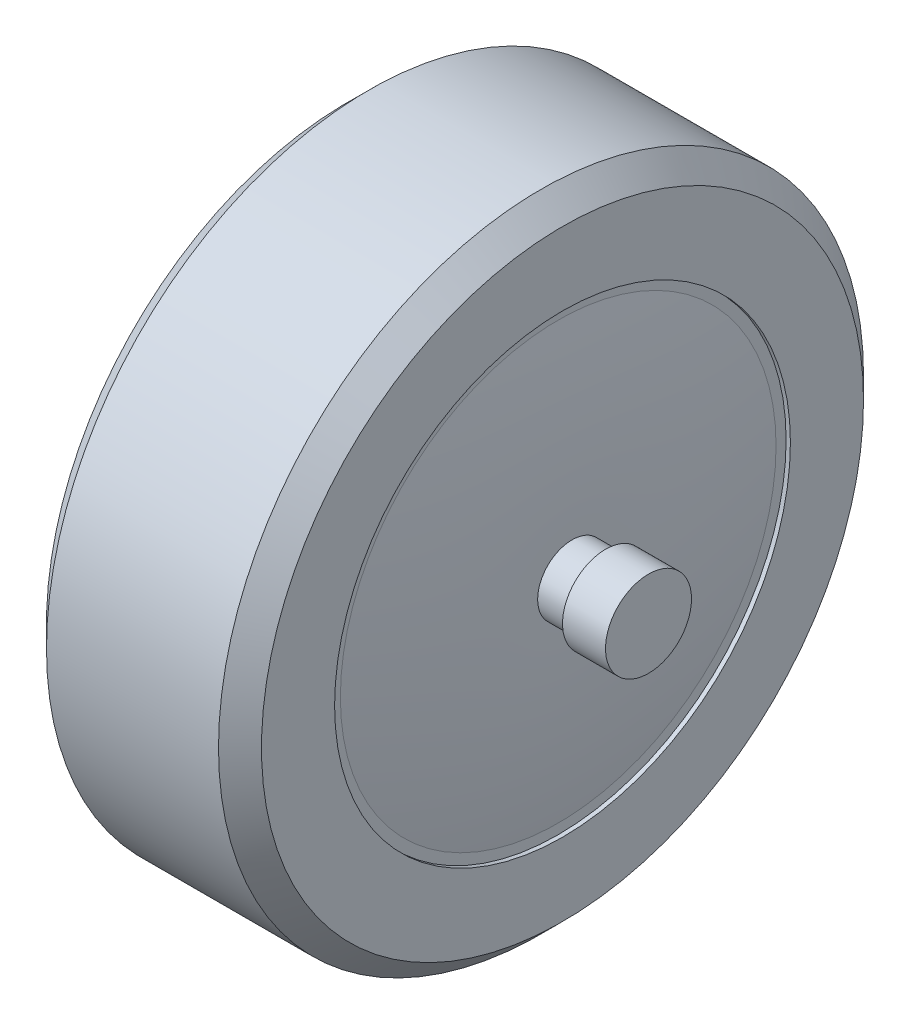
from build123d import *

# Parameters (mm, degrees)
SKETCH1_R           = 75
BOSS_EXTRUDE1_DEPTH = 25
SKETCH2_R           = 8
BOSS_EXTRUDE2_DEPTH = 35
SKETCH3_R           = 10
BOSS_EXTRUDE3_DEPTH = 10
CHAMFER1_SIZE       = 5
SKETCH4_R           = 53
SKETCH4_R_2         = 8
CUT_EXTRUDE1_DEPTH  = 1


with BuildPart() as part:
    # Sketch1 → Boss-Extrude1 (new body, symmetric)
    with BuildSketch(Plane(origin=(0, 0, 0), x_dir=(0, 0, -1), z_dir=(1, 0, 0))):
        Circle(SKETCH1_R)
    extrude(amount=BOSS_EXTRUDE1_DEPTH, both=True)

    # Sketch2 → Boss-Extrude2 (add, symmetric)
    with BuildSketch(Plane(origin=(0, 0, 0), x_dir=(0, 0, -1), z_dir=(1, 0, 0))):
        Circle(SKETCH2_R)
    extrude(amount=BOSS_EXTRUDE2_DEPTH, both=True)

    # Sketch3 → Boss-Extrude3 (add)
    with BuildSketch(Plane(origin=(35, 0, 0), x_dir=(0, 0, -1), z_dir=(1, 0, 0))):
        Circle(SKETCH3_R)
    boss_extrude3 = extrude(amount=BOSS_EXTRUDE3_DEPTH)

    # Mirror1: Boss-Extrude3 across plane
    add(boss_extrude3.mirror(Plane(origin=(0, 0, 0), x_dir=(0, 0, 1), z_dir=(1, 0, 0))))

    # Chamfer1
    chamfer1_edges = [part.edges().sort_by_distance(p)[0] for p in [
        (-25, 0, 75),
        (25, 0, 75),
    ]]
    chamfer(chamfer1_edges, length=CHAMFER1_SIZE)

    # Sketch4 → Cut-Extrude1 (cut)
    with BuildSketch(Plane(origin=(25, 0, 0), x_dir=(0, 0, -1), z_dir=(1, 0, 0))):
        Circle(SKETCH4_R)
        Circle(SKETCH4_R_2, mode=Mode.SUBTRACT)
    cut_extrude1 = extrude(amount=-CUT_EXTRUDE1_DEPTH, mode=Mode.SUBTRACT)

    # Mirror2: Cut-Extrude1 across plane
    add(cut_extrude1.mirror(Plane(origin=(0, 0, 0), x_dir=(0, 0, 1), z_dir=(1, 0, 0))), mode=Mode.SUBTRACT)

    # Sketch5 → Revolve1 (revolve)
    with BuildSketch(Plane(origin=(0, 0, 0), x_dir=(1, 0, 0), z_dir=(0, 1, 0))):
        with BuildLine():
            Line((24, 0), (24, 50.661166178))
            add(Edge.make_bspline(
                [(27, 0), (28.099596194, 25.463923128), (24, 50.661166178)],
                knots=[0, 0, 0, 1, 1, 1], degree=2))
            Line((27, 0), (24, 0))
        make_face()
    revolve1 = revolve(axis=Axis((27, 0, 0), (1, 0, 0)))

    # Mirror3: Revolve1 across plane
    add(revolve1.mirror(Plane(origin=(0, 0, 0), x_dir=(0, 0, 1), z_dir=(1, 0, 0))))


solid = part.part
